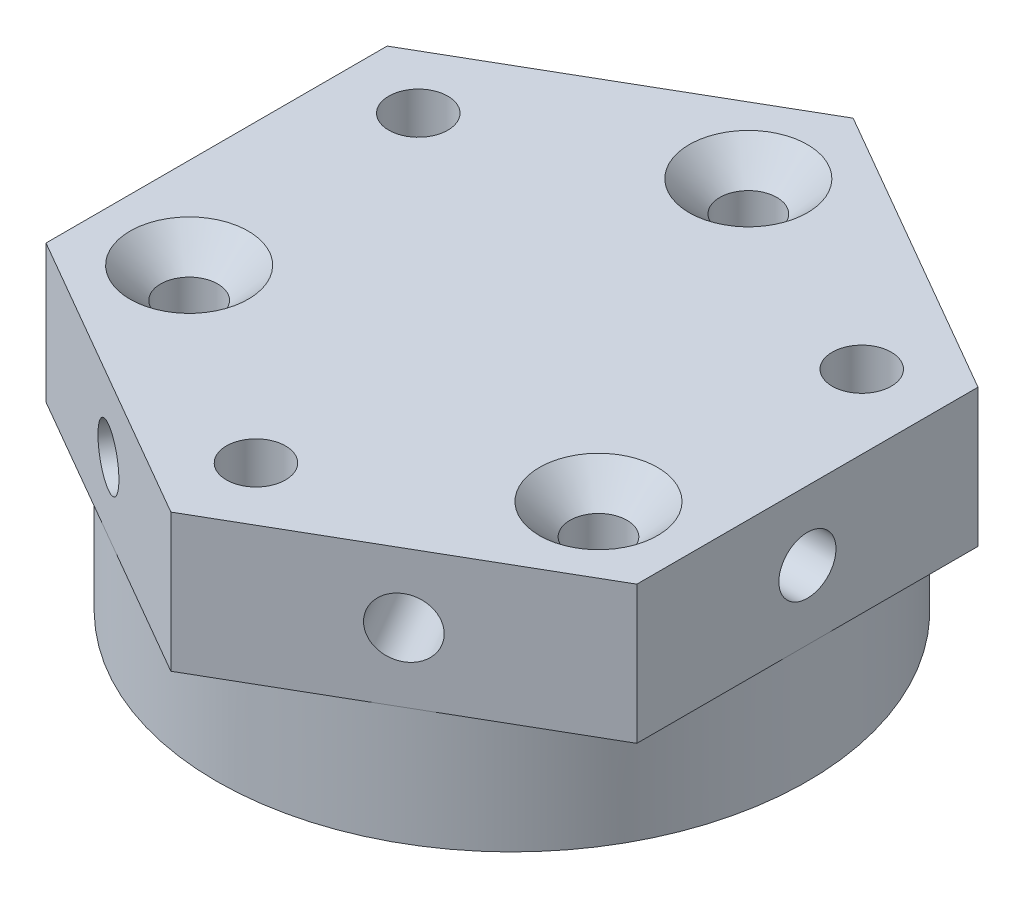
from build123d import *

# Parameters (mm, degrees)
SKETCH_1_R          = 15
SKETCH_1_R_2        = 1.45
SKETCH_1_R_3        = 1.5
EXTRUDE_1_DEPTH     = 13
SKETCH_2_R          = 1.45
SKETCH_2_R_2        = 1.5
EXTRUDE_2_DEPTH     = 7
SKETCH_3_R          = 1.45
CUT_EXTRUDE_1_DEPTH = 38.5
SKETCH_4_R          = 1.45
CUT_EXTRUDE_2_DEPTH = 38.5
SKETCH_5_R          = 1.45
CUT_EXTRUDE_3_DEPTH = 31
SKETCH_8_R          = 1.5
CUT_EXTRUDE_6_DEPTH = 38.5
CHAMFER_1_SIZE      = 1.55


with BuildPart() as part:
    # 草图1 → 凸台-拉伸1 (new body)
    with BuildSketch(Plane(origin=(0, 0, 0), x_dir=(1, 0, 0), z_dir=(0, 1, 0))):
        Circle(SKETCH_1_R)
        with Locations((0, 12)):
            Circle(SKETCH_1_R_2, mode=Mode.SUBTRACT)
        with Locations((-10.392304845, -6)):
            Circle(SKETCH_1_R_2, mode=Mode.SUBTRACT)
        with Locations((10.392304845, -6)):
            Circle(SKETCH_1_R_2, mode=Mode.SUBTRACT)
        with Locations((-11.258330249, 6.5)):
            Circle(SKETCH_1_R_3, mode=Mode.SUBTRACT)
        with Locations((0, -13)):
            Circle(SKETCH_1_R_3, mode=Mode.SUBTRACT)
        with Locations((11.258330249, 6.5)):
            Circle(SKETCH_1_R_3, mode=Mode.SUBTRACT)
    extrude(amount=EXTRUDE_1_DEPTH)

    # 草图2 → 凸台-拉伸2 (add)
    with BuildSketch(Plane(origin=(0, 13, 0), x_dir=(1, 0, 0), z_dir=(0, 1, 0))):
        Polygon((0, 17.320508076), (-15, 8.660254038), (-15, -8.660254038), (0, -17.320508076), (15, -8.660254038), (15, 8.660254038), align=None)
        with Locations((0, 12)):
            Circle(SKETCH_2_R, mode=Mode.SUBTRACT)
        with Locations((-11.258330249, 6.5)):
            Circle(SKETCH_2_R_2, mode=Mode.SUBTRACT)
        with Locations((11.258330249, 6.5)):
            Circle(SKETCH_2_R_2, mode=Mode.SUBTRACT)
        with Locations((-10.392304845, -6)):
            Circle(SKETCH_2_R, mode=Mode.SUBTRACT)
        with Locations((0, -13)):
            Circle(SKETCH_2_R_2, mode=Mode.SUBTRACT)
        with Locations((10.392304845, -6)):
            Circle(SKETCH_2_R, mode=Mode.SUBTRACT)
    extrude(amount=-EXTRUDE_2_DEPTH)

    # 草图3 → 切除-拉伸1 (cut, through all)
    with BuildSketch(Plane(origin=(7.5, 0, 12.990381057), x_dir=(0.866025404, 0, -0.5), z_dir=(0.5, 0, 0.866025404))):
        with Locations((0, 9.5)):
            Circle(SKETCH_3_R)
    extrude(amount=-CUT_EXTRUDE_1_DEPTH, mode=Mode.SUBTRACT)

    # 草图4 → 切除-拉伸2 (cut, through all)
    with BuildSketch(Plane(origin=(-7.5, 0, 12.990381057), x_dir=(0.866025404, 0, 0.5), z_dir=(-0.5, 0, 0.866025404))):
        with Locations((0, 9.5)):
            Circle(SKETCH_4_R)
    extrude(amount=-CUT_EXTRUDE_2_DEPTH, mode=Mode.SUBTRACT)

    # 草图5 → 切除-拉伸3 (cut, through all)
    with BuildSketch(Plane.ZY.offset(15)):
        with Locations((0, 9.5)):
            Circle(SKETCH_5_R)
    extrude(amount=-CUT_EXTRUDE_3_DEPTH, mode=Mode.SUBTRACT)

    # 草图8 → 切除-拉伸6 (cut, through all)
    with BuildSketch(Plane(origin=(-7.5, 0, -12.990381057), x_dir=(-0.866025404, 0, 0.5), z_dir=(-0.5, 0, -0.866025404))):
        with Locations((0, 9.5)):
            Circle(SKETCH_8_R)
    extrude(amount=-CUT_EXTRUDE_6_DEPTH, mode=Mode.SUBTRACT)

    # 倒角1
    chamfer_1_edges = [part.edges().sort_by_distance(p)[0] for p in [
        (8.942304845, 13, 6),
        (-1.45, 13, -12),
        (-11.842304845, 13, 6),
    ]]
    chamfer(chamfer_1_edges, length=CHAMFER_1_SIZE)


solid = part.part
